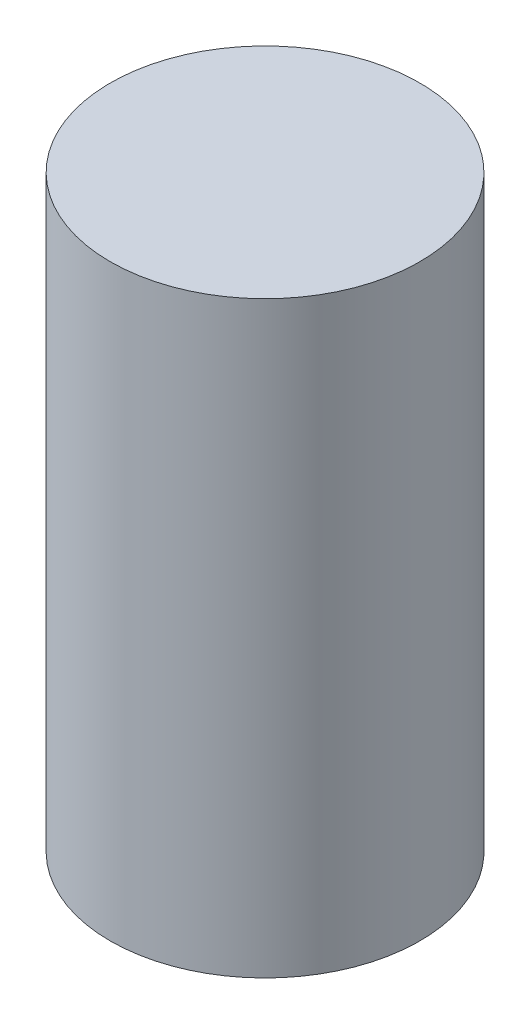
from build123d import *

# Parameters (mm, degrees)
SKETCH1_R           = 6.35
BOSS_EXTRUDE1_DEPTH = 24.13


with BuildPart() as part:
    # Sketch1 → Boss-Extrude1 (new body)
    with BuildSketch(Plane(origin=(0, 0, 0), x_dir=(1, 0, 0), z_dir=(0, 1, 0))):
        Circle(SKETCH1_R)
    extrude(amount=BOSS_EXTRUDE1_DEPTH)


solid = part.part
